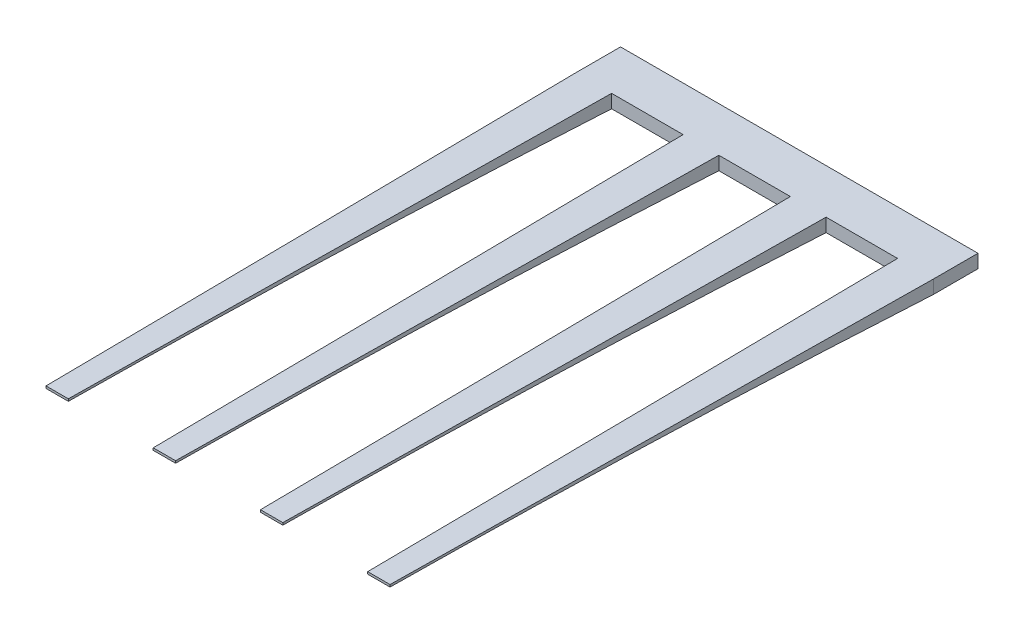
from build123d import *

# Parameters (mm, degrees)
SKETCH5_W           = 1600
SKETCH5_H           = 60
BOSS_EXTRUDE2_DEPTH = 200
SKETCH7_W           = 160
SKETCH7_H           = 60
SKETCH9_W           = 130
SKETCH9_H           = 20
SKETCH10_W          = 100
SKETCH10_H          = 10
LPATTERN1_COUNT     = 4
LPATTERN1_PITCH     = 480


with BuildPart() as part:
    # Sketch5 → Boss-Extrude2 (new body)
    with BuildSketch(Plane.XY):
        with Locations((800, -30)):
            Rectangle(SKETCH5_W, SKETCH5_H)
    extrude(amount=BOSS_EXTRUDE2_DEPTH)

    # Sketch7 → Loft1 section 0
    with BuildSketch(Plane.XY.offset(200)):
        with Locations((80, -30)):
            Rectangle(SKETCH7_W, SKETCH7_H)
    # Sketch9 → Loft1 section 1
    with BuildSketch(Plane.XY.offset(1400)):
        with Locations((80, -10)):
            Rectangle(SKETCH9_W, SKETCH9_H)
    # Sketch10 → Loft1 section 2
    with BuildSketch(Plane.XY.offset(2600)):
        with Locations((78.227130787, -5)):
            Rectangle(SKETCH10_W, SKETCH10_H)
    loft1 = loft()

    # LPattern1: Loft1 ×4
    with Locations(*[(i * LPATTERN1_PITCH, 0, 0) for i in range(1, LPATTERN1_COUNT)]):
        add(loft1)


solid = part.part
